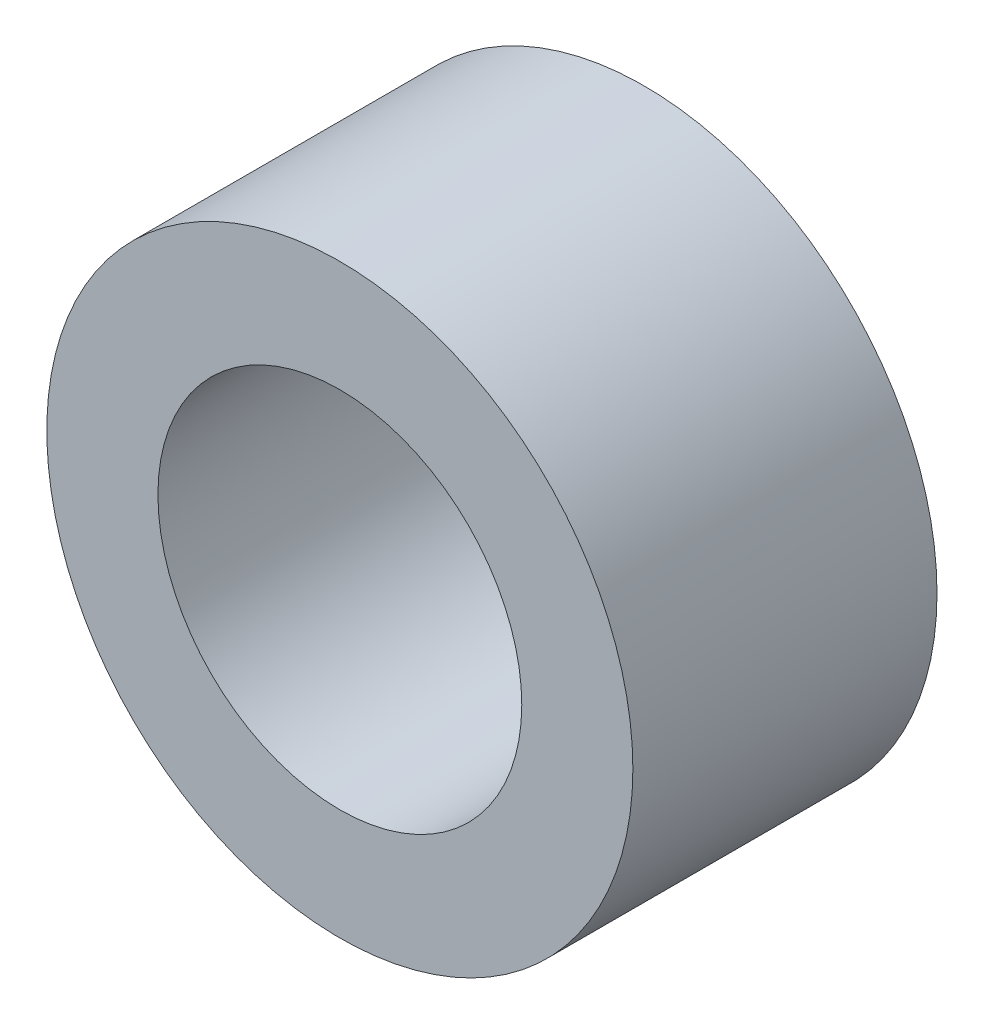
from build123d import *

# Parameters (mm, degrees)
SKETCH1_W = 2.032
SKETCH1_H = 5.5626


with BuildPart() as part:
    # Sketch1 → Revolve1 (revolve)
    with BuildSketch(Plane(origin=(0, 320.521396786, 0), x_dir=(1, 0, 0), z_dir=(0, 1, 0))):
        with Locations((4.3434, 2.7813)):
            Rectangle(SKETCH1_W, SKETCH1_H)
    revolve(axis=Axis((0, 320.521396786, -5.5626), (0, 0, 1)))


solid = part.part
